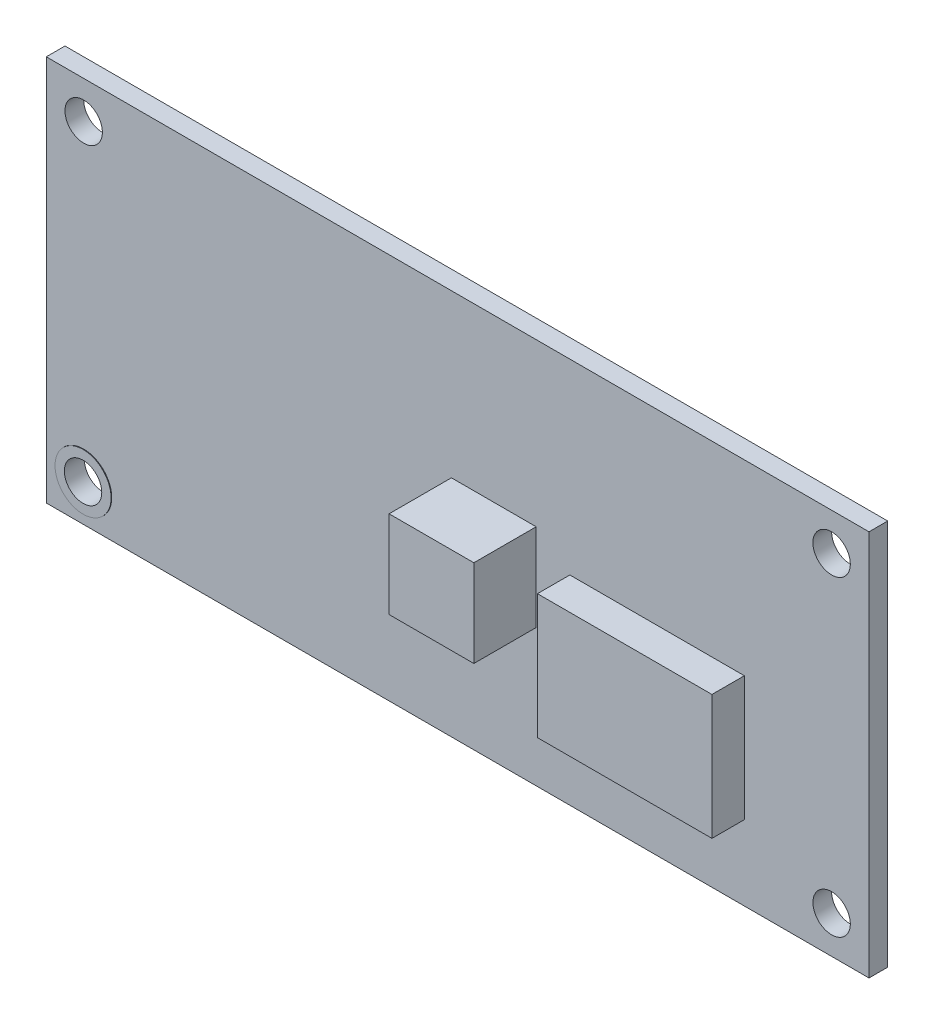
from build123d import *

# Parameters (mm, degrees)
SKETCH1_W           = 66
SKETCH1_H           = 31
SKETCH1_R           = 1.5
BOSS_EXTRUDE1_DEPTH = 1.5
SKETCH2_W           = 14
SKETCH2_H           = 10
BOSS_EXTRUDE2_DEPTH = 2.6
SKETCH3_W           = 6.8
SKETCH3_H           = 7
BOSS_EXTRUDE3_DEPTH = 5
SKETCH4_R           = 2.25
SKETCH4_R_2         = 1.5
BOSS_EXTRUDE4_DEPTH = 0.05
SKETCH5_W           = 5.2
SKETCH5_H           = 10
SKETCH5_W_2         = 3.6
SKETCH5_H_2         = 8.4
BOSS_EXTRUDE5_DEPTH = 10.7
CHAMFER1_SIZE       = 1
FILLET1_R           = 1.5
SKETCH6_R           = 1.5
BOSS_EXTRUDE6_DEPTH = 2
CHAMFER2_SIZE       = 1


with BuildPart() as part:
    # Sketch1 → Boss-Extrude1 (new body)
    with BuildSketch(Plane.XY):
        Rectangle(SKETCH1_W, SKETCH1_H)
        with Locations((30, 12.5)):
            Circle(SKETCH1_R, mode=Mode.SUBTRACT)
        with Locations((30, -12.5)):
            Circle(SKETCH1_R, mode=Mode.SUBTRACT)
        with Locations((-30, -12.5)):
            Circle(SKETCH1_R, mode=Mode.SUBTRACT)
        with Locations((-30, 12.5)):
            Circle(SKETCH1_R, mode=Mode.SUBTRACT)
    extrude(amount=BOSS_EXTRUDE1_DEPTH)

    # Sketch2 → Boss-Extrude2 (add)
    with BuildSketch(Plane.XY.offset(1.5)):
        with Locations((16, -4.5)):
            Rectangle(SKETCH2_W, SKETCH2_H)
    extrude(amount=BOSS_EXTRUDE2_DEPTH)

    # Sketch3 → Boss-Extrude3 (add)
    with BuildSketch(Plane.XY.offset(1.5)):
        with Locations((2.9, -1)):
            Rectangle(SKETCH3_W, SKETCH3_H)
    extrude(amount=BOSS_EXTRUDE3_DEPTH)

    # Sketch4 → Boss-Extrude4 (add)
    with BuildSketch(Plane.XY.offset(1.5)):
        with Locations((-30, -12.5)):
            Circle(SKETCH4_R)
        with Locations((-30, -12.5)):
            Circle(SKETCH4_R_2, mode=Mode.SUBTRACT)
    boss_extrude4 = extrude(amount=BOSS_EXTRUDE4_DEPTH)

    # Mirror1: Boss-Extrude4 across plane
    add(boss_extrude4.mirror(Plane.XY.offset(0.75)))

    # Sketch5 → Boss-Extrude5 (add)
    with BuildSketch(Plane(origin=(0, 0, 0), x_dir=(-1, 0, 0), z_dir=(0, 0, -1))):
        with Locations((22.3, -9)):
            Rectangle(SKETCH5_W, SKETCH5_H)
        with Locations((22.3, -9)):
            Rectangle(SKETCH5_W_2, SKETCH5_H_2, mode=Mode.SUBTRACT)
    extrude(amount=BOSS_EXTRUDE5_DEPTH)

    # Chamfer1
    chamfer1_edges = [part.edges().sort_by_distance(p)[0] for p in [
        (-24.1, -4.8, -5.35),
        (-20.5, -4.8, -5.35),
    ]]
    chamfer(chamfer1_edges, length=CHAMFER1_SIZE)

    # Fillet1
    fillet1_edges = [part.edges().sort_by_distance(p)[0] for p in [
        (-24.9, -4, -5.35),
        (-19.7, -4, -5.35),
    ]]
    fillet(fillet1_edges, radius=FILLET1_R)

    # Sketch6 → Boss-Extrude6 (add)
    with BuildSketch(Plane(origin=(0, 0, 0), x_dir=(-1, 0, 0), z_dir=(0, 0, -1))):
        with Locations((16, 12.5)):
            Circle(SKETCH6_R)
        with Locations((22, 12.5)):
            Circle(SKETCH6_R)
    extrude(amount=BOSS_EXTRUDE6_DEPTH)

    # Chamfer2
    chamfer2_edges = [part.edges().sort_by_distance(p)[0] for p in [
        (-14.5, 12.5, -2),
        (-20.5, 12.5, -2),
    ]]
    chamfer(chamfer2_edges, length=CHAMFER2_SIZE)


solid = part.part
